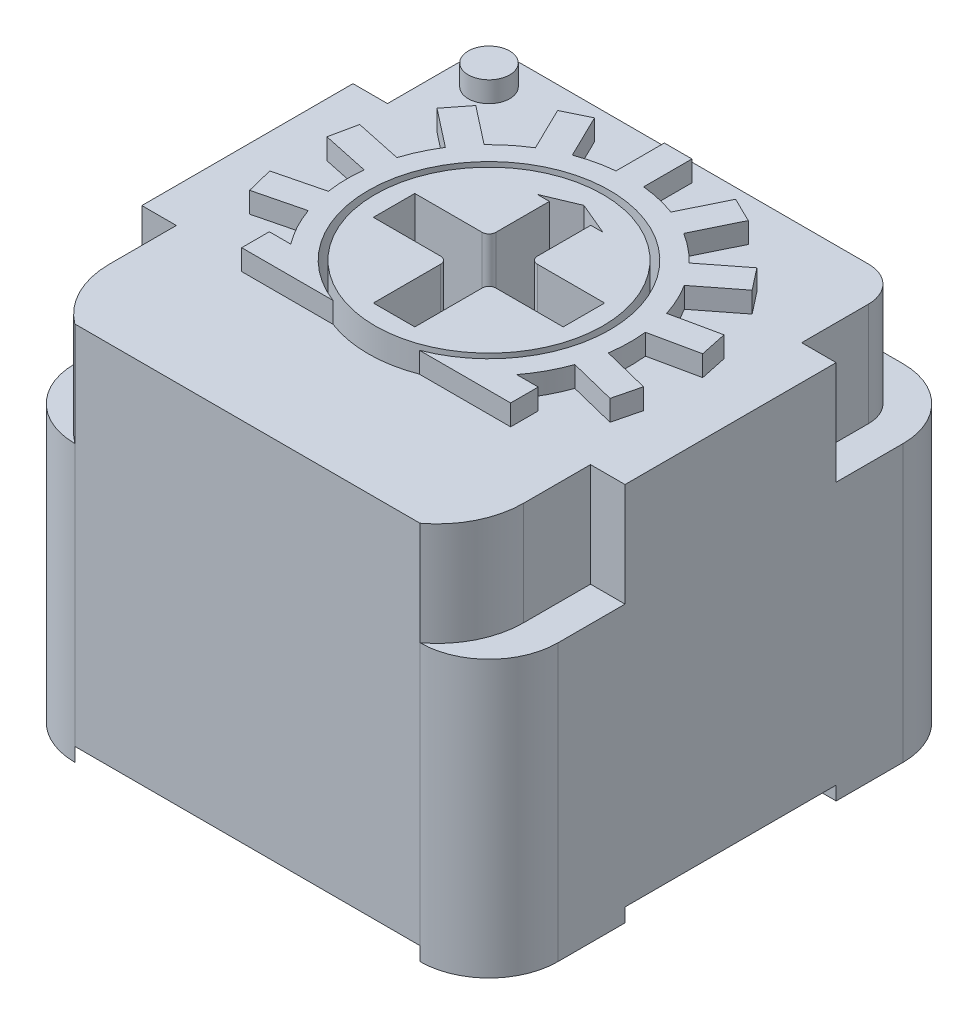
from build123d import *

# Parameters (mm, degrees)
BOSS_EXTRUDE1_DEPTH             = 5.5
SKETCH3_R                       = 1.75
CUT_EXTRUDE1_DEPTH              = 1.75
SKETCH4_R                       = 1.65
BOSS_EXTRUDE2_DEPTH             = 2.05
CUT_EXTRUDE2_DEPTH              = 1.6
FILLET1_R                       = 0.1
BOSS_EXTRUDE3_DEPTH             = 0.3
SKETCH7_R                       = 0.3
BOSS_EXTRUDE4_DEPTH             = 0.3
CUT_EXTRUDE3_DEPTH              = 1.5
FILLET2_R                       = 0.5
CUT_EXTRUDE7_DEPTH              = 0.2
SKETCH11_R                      = 0.225
BOSS_EXTRUDE6_DEPTH             = 7.2
BOSS_EXTRUDE6_2_DEPTH           = 7.2
BOSS_EXTRUDE6_3_DEPTH           = 7.2
SKIZZE2_W                       = 11.62513836
SKIZZE2_H                       = 10.386388006
SCHNITT_LINEAR_AUSTRAGEN1_DEPTH = 7


with BuildPart() as part:
    # Sketch1 → Boss-Extrude1 (new body)
    with BuildSketch(Plane(origin=(0, 0, 0), x_dir=(1, 0, 0), z_dir=(0, 1, 0))):
        with BuildLine():
            Line((2.5, -3.5), (-2.5, -3.5))
            ThreePointArc((-2.5, -3.5), (-3.207106781, -3.207106781), (-3.5, -2.5))
            Line((-3.5, -2.5), (-3.5, 2.5))
            ThreePointArc((-3.5, 2.5), (-3.207106781, 3.207106781), (-2.5, 3.5))
            Line((-2.5, 3.5), (2.5, 3.5))
            ThreePointArc((2.5, 3.5), (3.207106781, 3.207106781), (3.5, 2.5))
            Line((3.5, 2.5), (3.5, -2.5))
            ThreePointArc((3.5, -2.5), (3.207106781, -3.207106781), (2.5, -3.5))
        make_face()
    extrude(amount=BOSS_EXTRUDE1_DEPTH)

    # Sketch3 → Cut-Extrude1 (cut)
    with BuildSketch(Plane(origin=(0, 5.5, 0), x_dir=(1, 0, 0), z_dir=(0, 1, 0))):
        Circle(SKETCH3_R)
    extrude(amount=-CUT_EXTRUDE1_DEPTH, mode=Mode.SUBTRACT)

    # Sketch6 → Boss-Extrude3 (add)
    with BuildSketch(Plane(origin=(0, 5.5, 0), x_dir=(1, 0, 0), z_dir=(0, 1, 0))):
        with BuildLine():
            Line((-0.625, -1.634587104), (-1.948025053, -1.634587104))
            Line((-1.948025053, -1.634587104), (-1.948025053, -1.234587104))
            Line((-1.948025053, -1.234587104), (-1.636549627, -1.234587104))
            ThreePointArc((-1.636549627, -1.234587104), (-1.804732041, -0.972338553), (-1.931232927, -0.687633175))
            Line((-1.931232927, -0.687633175), (-2.610439935, -0.856978501))
            Line((-2.610439935, -0.856978501), (-2.707208693, -0.468860211))
            Line((-2.707208693, -0.468860211), (-2.028001685, -0.299514884))
            ThreePointArc((-2.028001685, -0.299514884), (-2.049687775, -0.035777433), (-2.0372192, 0.22855619))
            Line((-2.0372192, 0.22855619), (-2.72192252, 0.374094373))
            Line((-2.72192252, 0.374094373), (-2.638757844, 0.765353413))
            Line((-2.638757844, 0.765353413), (-1.954054524, 0.61981523))
            ThreePointArc((-1.954054524, 0.61981523), (-1.857930963, 0.866367437), (-1.730848049, 1.098483059))
            Line((-1.730848049, 1.098483059), (-2.282455576, 1.529446092))
            Line((-2.282455576, 1.529446092), (-2.036190986, 1.844650393))
            Line((-2.036190986, 1.844650393), (-1.484583459, 1.413687361))
            ThreePointArc((-1.484583459, 1.413687361), (-1.290106802, 1.593149221), (-1.074132643, 1.746063878))
            Line((-1.074132643, 1.746063878), (-1.380992446, 2.37521971))
            Line((-1.380992446, 2.37521971), (-1.021474827, 2.550568169))
            Line((-1.021474827, 2.550568169), (-0.714615024, 1.921412336))
            ThreePointArc((-0.714615024, 1.921412336), (-0.461149661, 1.997458633), (-0.2, 2.040220576))
            Line((-0.2, 2.040220576), (-0.2, 2.740220576))
            Line((-0.2, 2.740220576), (0.2, 2.740220576))
            Line((0.2, 2.740220576), (0.2, 2.040220576))
            ThreePointArc((0.2, 2.040220576), (0.461149661, 1.997458633), (0.714615024, 1.921412336))
            Line((0.714615024, 1.921412336), (1.021474827, 2.550568169))
            Line((1.021474827, 2.550568169), (1.380992446, 2.37521971))
            Line((1.380992446, 2.37521971), (1.074132643, 1.746063878))
            ThreePointArc((1.074132643, 1.746063878), (1.290106802, 1.593149221), (1.484583459, 1.413687361))
            Line((1.484583459, 1.413687361), (2.036190986, 1.844650393))
            Line((2.036190986, 1.844650393), (2.282455576, 1.529446092))
            Line((2.282455576, 1.529446092), (1.730848049, 1.098483059))
            ThreePointArc((1.730848049, 1.098483059), (1.857930963, 0.866367437), (1.954054524, 0.61981523))
            Line((1.954054524, 0.61981523), (2.638757844, 0.765353413))
            Line((2.638757844, 0.765353413), (2.72192252, 0.374094373))
            Line((2.72192252, 0.374094373), (2.0372192, 0.22855619))
            ThreePointArc((2.0372192, 0.22855619), (2.049687775, -0.035777433), (2.028001685, -0.299514884))
            Line((2.028001685, -0.299514884), (2.707208693, -0.468860211))
            Line((2.707208693, -0.468860211), (2.610439935, -0.856978501))
            Line((2.610439935, -0.856978501), (1.931232927, -0.687633175))
            ThreePointArc((1.931232927, -0.687633175), (1.804732041, -0.972338553), (1.636549627, -1.234587104))
            Line((1.636549627, -1.234587104), (1.948025053, -1.234587104))
            Line((1.948025053, -1.234587104), (1.948025053, -1.634587104))
            Line((1.948025053, -1.634587104), (0.625, -1.634587104))
            ThreePointArc((0.625, -1.634587104), (0, 1.75), (-0.625, -1.634587104))
        make_face()
    extrude(amount=BOSS_EXTRUDE3_DEPTH)

    # Sketch7 → Boss-Extrude4 (add)
    with BuildSketch(Plane(origin=(0, 5.5, 0), x_dir=(1, 0, 0), z_dir=(0, 1, 0))):
        with Locations((-2.474873734, 2.474873734)):
            Circle(SKETCH7_R)
    extrude(amount=BOSS_EXTRUDE4_DEPTH)

    # Sketch2 → Cut-Extrude3 (cut)
    with BuildSketch(Plane(origin=(0, 5.5, 0), x_dir=(1, 0, 0), z_dir=(0, 1, 0))):
        with BuildLine():
            ThreePointArc((-3.5, -2.5), (-3.207106781, -3.207106781), (-2.5, -3.5))
            ThreePointArc((-2.5, -3.5), (-2.868033989, -3.059016994), (-3, -2.5))
            Line((-3, -2.5), (-3, -1.529446092))
            Line((-3, -1.529446092), (-3.5, -1.529446092))
            Line((-3.5, -1.529446092), (-3.5, -2.5))
        make_face()
        with BuildLine():
            ThreePointArc((2.5, -3.5), (3.207106781, -3.207106781), (3.5, -2.5))
            Line((3.5, -2.5), (3.5, -1.529446092))
            Line((3.5, -1.529446092), (3, -1.529446092))
            Line((3, -1.529446092), (3, -2.5))
            ThreePointArc((3, -2.5), (2.868033989, -3.059016994), (2.5, -3.5))
        make_face()
        with BuildLine():
            Line((3, 1.529446092), (3.5, 1.529446092))
            Line((3.5, 1.529446092), (3.5, 2.5))
            ThreePointArc((3.5, 2.5), (3.207106781, 3.207106781), (2.5, 3.5))
            Line((2.5, 3.5), (-2.5, 3.5))
            ThreePointArc((-2.5, 3.5), (-3.207106781, 3.207106781), (-3.5, 2.5))
            Line((-3.5, 2.5), (-3.5, 1.529446092))
            Line((-3.5, 1.529446092), (-3, 1.529446092))
            Line((-3, 1.529446092), (-3, 3))
            Line((-3, 3), (3, 3))
            Line((3, 3), (3, 1.529446092))
        make_face()
    extrude(amount=-CUT_EXTRUDE3_DEPTH, mode=Mode.SUBTRACT)

    # Fillet2
    fillet2_edges = [part.edges().sort_by_distance(p)[0] for p in [
        (3, 4.75, -3),
        (-3, 4.75, -3),
    ]]
    fillet(fillet2_edges, radius=FILLET2_R)

    # Sketch10 → Cut-Extrude7 (cut)
    with BuildSketch(Plane(origin=(0, 0, 0), x_dir=(1, 0, 0), z_dir=(0, 1, 0))):
        with BuildLine():
            Line((3, 2.5), (3, 1.529446092))
            Line((3, 1.529446092), (3.5, 1.529446092))
            Line((3.5, 1.529446092), (3.5, -1.529446092))
            Line((3.5, -1.529446092), (3, -1.529446092))
            Line((3, -1.529446092), (3, -2.5))
            ThreePointArc((3, -2.5), (2.868033989, -3.059016994), (2.5, -3.5))
            Line((2.5, -3.5), (-2.5, -3.5))
            ThreePointArc((-2.5, -3.5), (-2.868033989, -3.059016994), (-3, -2.5))
            Line((-3, -2.5), (-3, -1.529446092))
            Line((-3, -1.529446092), (-3.5, -1.529446092))
            Line((-3.5, -1.529446092), (-3.5, 1.529446092))
            Line((-3.5, 1.529446092), (-3, 1.529446092))
            Line((-3, 1.529446092), (-3, 2.5))
            ThreePointArc((-3, 2.5), (-2.853553391, 2.853553391), (-2.5, 3))
            Line((-2.5, 3), (2.5, 3))
            ThreePointArc((2.5, 3), (2.853553391, 2.853553391), (3, 2.5))
        make_face()
    extrude(amount=CUT_EXTRUDE7_DEPTH, mode=Mode.SUBTRACT)


with BuildPart() as body_2:
    # Sketch4 → Boss-Extrude2 (new body)
    with BuildSketch(Plane(origin=(0, 3.75, 0), x_dir=(1, 0, 0), z_dir=(0, 1, 0))):
        Circle(SKETCH4_R)
    extrude(amount=BOSS_EXTRUDE2_DEPTH)

    # Sketch5 → Cut-Extrude2 (cut)
    with BuildSketch(Plane(origin=(0, 5.8, 0), x_dir=(1, 0, 0), z_dir=(0, 1, 0))):
        Polygon((-0.3, 0.3), (-0.3, 1.175), (-0.475, 1.175), (0, 1.375), (0.475, 1.175), (0.3, 1.175), (0.3, 0.3), (1.375, 0.3), (1.375, -0.3), (0.3, -0.3), (0.3, -1.375), (-0.3, -1.375), (-0.3, -0.3), (-1.375, -0.3), (-1.375, 0.3), align=None)
    extrude(amount=-CUT_EXTRUDE2_DEPTH, mode=Mode.SUBTRACT)

    # Fillet1
    fillet1_edges = [body_2.edges().sort_by_distance(p)[0] for p in [
        (-0.3, 5, -0.3),
        (0.3, 5, -0.3),
        (0.3, 5, 0.3),
        (-0.3, 5, 0.3),
    ]]
    fillet(fillet1_edges, radius=FILLET1_R)


with BuildPart() as body_3:
    # Sketch11 → Boss-Extrude6 (new body)
    with BuildSketch(Plane.XZ.offset(-0.2)):
        with Locations((2.5, 0)):
            Circle(SKETCH11_R)
    extrude(amount=BOSS_EXTRUDE6_DEPTH)


with BuildPart() as body_4:
    # Sketch11 → Boss-Extrude6 2 (new body)
    with BuildSketch(Plane.XZ.offset(-0.2)):
        with Locations((0, -2.5)):
            Circle(SKETCH11_R)
    extrude(amount=BOSS_EXTRUDE6_2_DEPTH)


with BuildPart() as body_5:
    # Sketch11 → Boss-Extrude6 3 (new body)
    with BuildSketch(Plane.XZ.offset(-0.2)):
        with Locations((-2.5, 0)):
            Circle(SKETCH11_R)
    extrude(amount=BOSS_EXTRUDE6_3_DEPTH)


with BuildPart() as schnitt_linear_austragen1_tool:
    # Skizze2 → Schnitt-Linear austragen1 (new body)
    with BuildSketch(Plane.XZ.offset(7)):
        with Locations((-1.384709973, -1.375039125)):
            Rectangle(SKIZZE2_W, SKIZZE2_H)
    extrude(amount=-SCHNITT_LINEAR_AUSTRAGEN1_DEPTH)


with BuildPart() as body_3_1:
    add(body_3.part)

    # Schnitt-Linear austragen1: cut by schnitt_linear_austragen1_tool
    add(schnitt_linear_austragen1_tool.part, mode=Mode.SUBTRACT)


with BuildPart() as body_4_1:
    add(body_4.part)

    # Schnitt-Linear austragen1: cut by schnitt_linear_austragen1_tool
    add(schnitt_linear_austragen1_tool.part, mode=Mode.SUBTRACT)


with BuildPart() as body_5_1:
    add(body_5.part)

    # Schnitt-Linear austragen1: cut by schnitt_linear_austragen1_tool
    add(schnitt_linear_austragen1_tool.part, mode=Mode.SUBTRACT)


solid = Compound([part.part, body_2.part, body_3_1.part, body_4_1.part, body_5_1.part])
